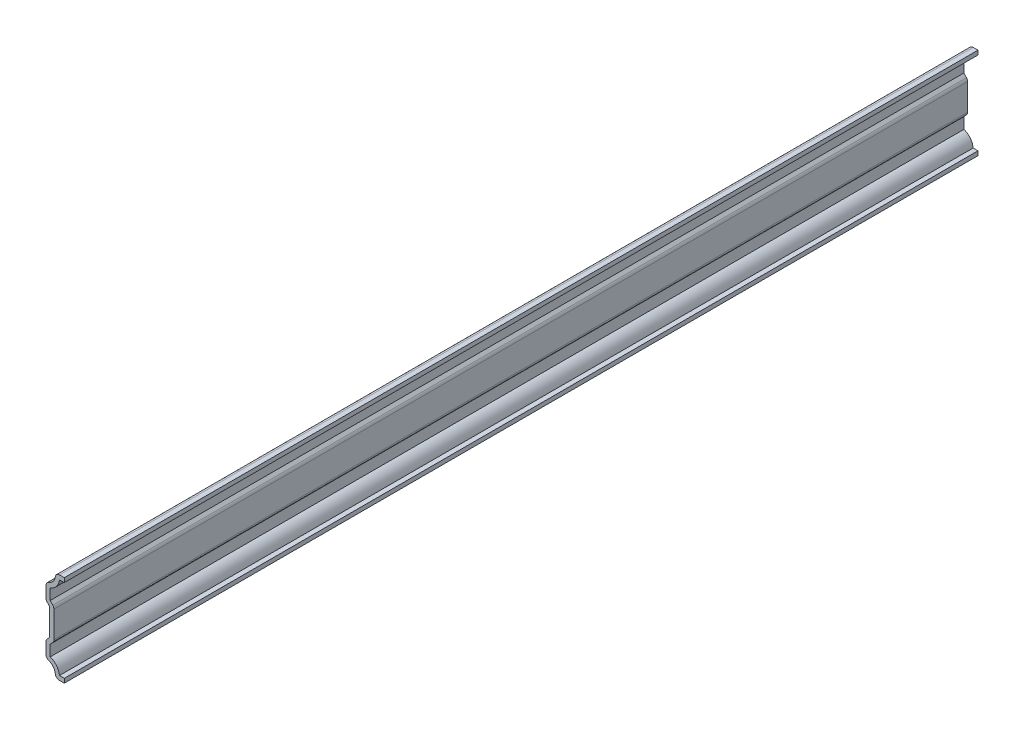
from build123d import *

# Parameters (mm, degrees)
EXTRUDE_THIN1_DEPTH = 357.1875
FILLET1_R           = 1.651


with BuildPart() as part:
    # Sketch1 → Extrude-Thin1 (new body)
    with BuildSketch(Plane.XY):
        with BuildLine():
            Line((0, 0), (-3.697192387, 0))
            ThreePointArc((-3.697192387, 0), (-4.204355265, 3.261336848), (-7.14375, 4.7625))
            Line((-7.14375, 4.7625), (-7.14375, 11.1125))
            Line((-7.14375, 11.1125), (-5.715, 12.668334975))
            Line((-5.715, 12.668334975), (-5.715, 23.050415025))
            Line((-5.715, 23.050415025), (-7.14375, 24.60625))
            Line((-7.14375, 24.60625), (-7.14375, 30.95625))
            ThreePointArc((-7.14375, 30.95625), (-4.204355265, 32.457413152), (-3.697192387, 35.71875))
            Line((-3.697192387, 35.71875), (0, 35.71875))
            Line((0, 35.71875), (0, 34.06775))
            Line((0, 34.06775), (-1.889748251, 34.06775))
            ThreePointArc((-1.889748251, 34.06775), (-3.02342288, 31.283918913), (-5.49275, 29.570046904))
            Line((-5.49275, 29.570046904), (-5.49275, 25.249313927))
            Line((-5.49275, 25.249313927), (-4.064, 23.693478952))
            Line((-4.064, 23.693478952), (-4.064, 12.025271048))
            Line((-4.064, 12.025271048), (-5.49275, 10.469436073))
            Line((-5.49275, 10.469436073), (-5.49275, 6.148703096))
            ThreePointArc((-5.49275, 6.148703096), (-3.02342288, 4.434831087), (-1.889748251, 1.651))
            Line((-1.889748251, 1.651), (0, 1.651))
            Line((0, 1.651), (0, 0))
        make_face()
    extrude(amount=-EXTRUDE_THIN1_DEPTH)

    # Fillet1
    fillet1_edges = [part.edges().sort_by_distance(p)[0] for p in [
        (-3.697192387, 0, -178.59375),
        (-7.14375, 4.7625, -178.59375),
        (-7.14375, 11.1125, -178.59375),
        (-7.14375, 24.60625, -178.59375),
        (-7.14375, 30.95625, -178.59375),
        (-3.697192387, 35.71875, -178.59375),
        (-4.064, 23.693478952, -178.59375),
        (-4.064, 12.025271048, -178.59375),
    ]]
    fillet(fillet1_edges, radius=FILLET1_R)


solid = part.part
